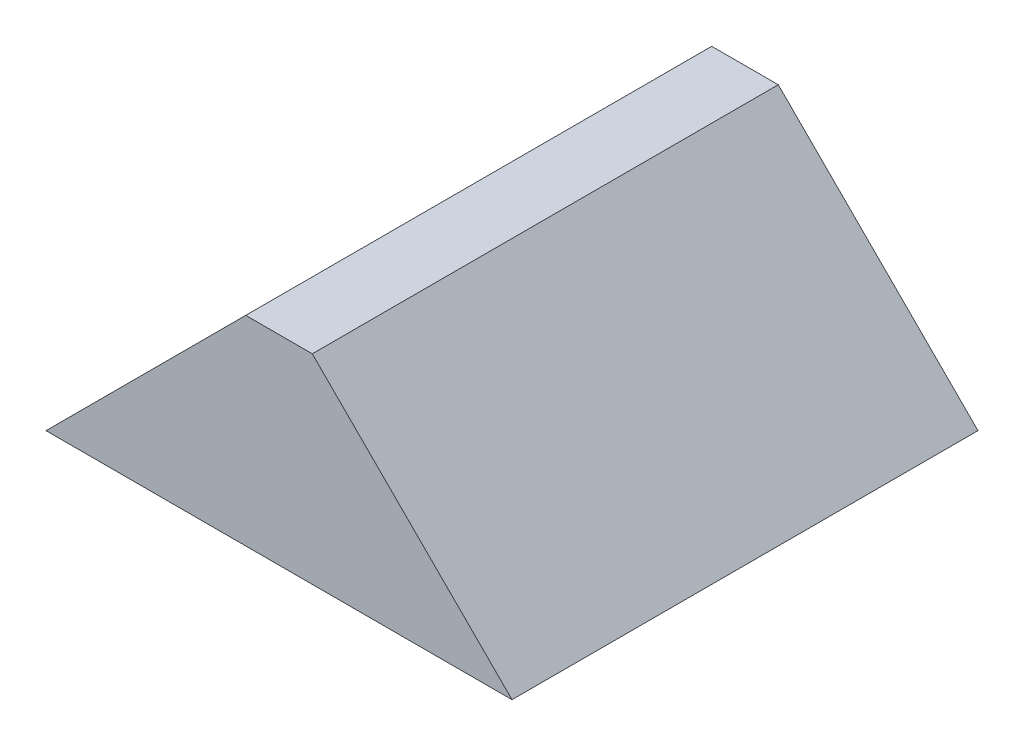
from build123d import *

# Parameters (mm, degrees)
SKETCH1_W           = 88.9
SKETCH1_H           = 88.9
BOSS_EXTRUDE1_DEPTH = 38.1
CUT_EXTRUDE1_DEPTH  = 89.9


with BuildPart() as part:
    # Sketch1 → Boss-Extrude1 (new body)
    with BuildSketch(Plane(origin=(0, 0, 0), x_dir=(1, 0, 0), z_dir=(0, 1, 0))):
        with Locations((44.45, 44.45)):
            Rectangle(SKETCH1_W, SKETCH1_H)
    extrude(amount=BOSS_EXTRUDE1_DEPTH)

    # Sketch2 → Cut-Extrude1 (cut, through all)
    with BuildSketch(Plane.XY):
        Polygon((0, 0), (38.1, 38.1), (0, 38.1), align=None)
        Polygon((88.9, 0), (88.9, 38.1), (50.8, 38.1), align=None)
    extrude(amount=-CUT_EXTRUDE1_DEPTH, mode=Mode.SUBTRACT)


solid = part.part
